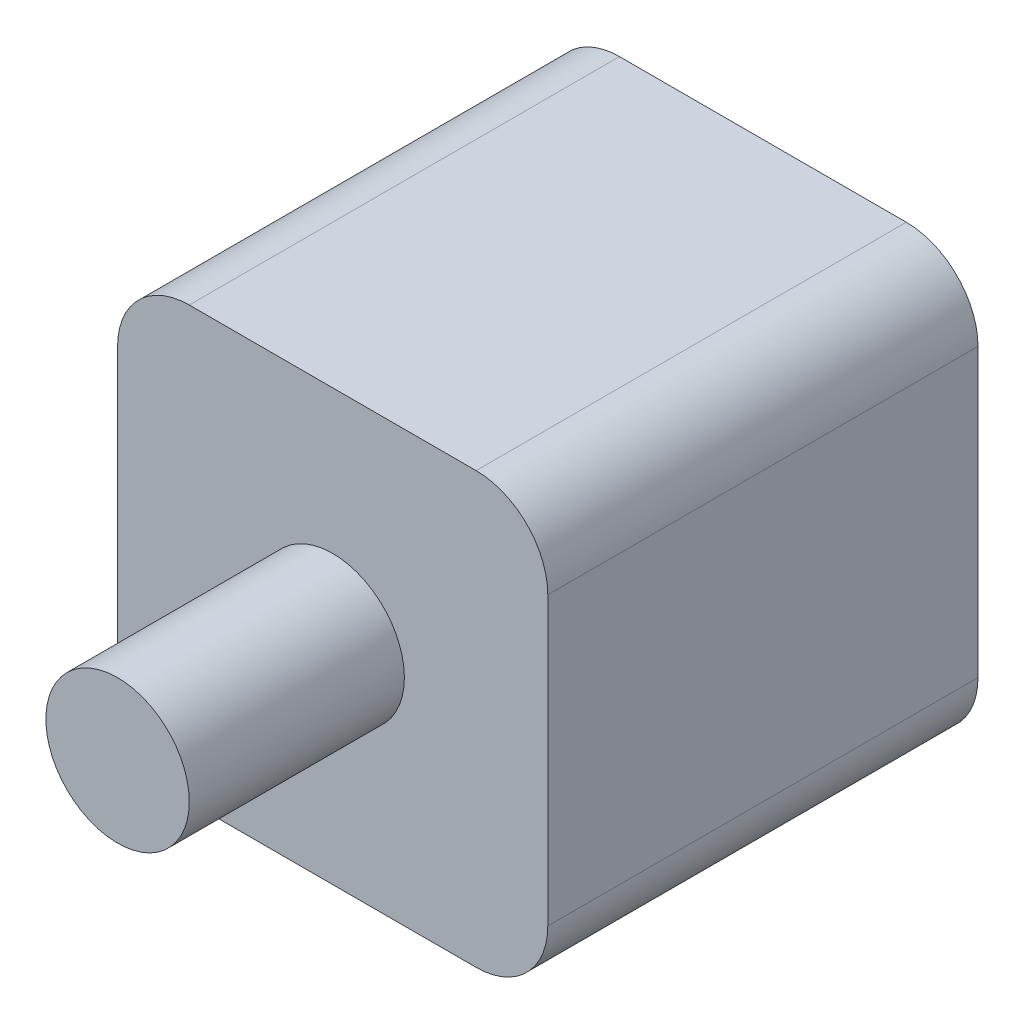
from build123d import *

# Parameters (mm, degrees)
SKETCH1_W           = 60
SKETCH1_H           = 60
BOSS_EXTRUDE1_DEPTH = 30
SKETCH2_R           = 10
BOSS_EXTRUDE2_DEPTH = 30
FILLET1_R           = 10


with BuildPart() as part:
    # Sketch1 → Boss-Extrude1 (new body, symmetric)
    with BuildSketch(Plane.XY):
        Rectangle(SKETCH1_W, SKETCH1_H)
    extrude(amount=BOSS_EXTRUDE1_DEPTH, both=True)

    # Sketch2 → Boss-Extrude2 (add)
    with BuildSketch(Plane.XY.offset(30)):
        Circle(SKETCH2_R)
    extrude(amount=BOSS_EXTRUDE2_DEPTH)

    # Fillet1
    fillet1_edges = [part.edges().sort_by_distance(p)[0] for p in [
        (30, -30, 0),
        (-30, -30, 0),
        (-30, 30, 0),
        (30, 30, 0),
    ]]
    fillet(fillet1_edges, radius=FILLET1_R)


solid = part.part
